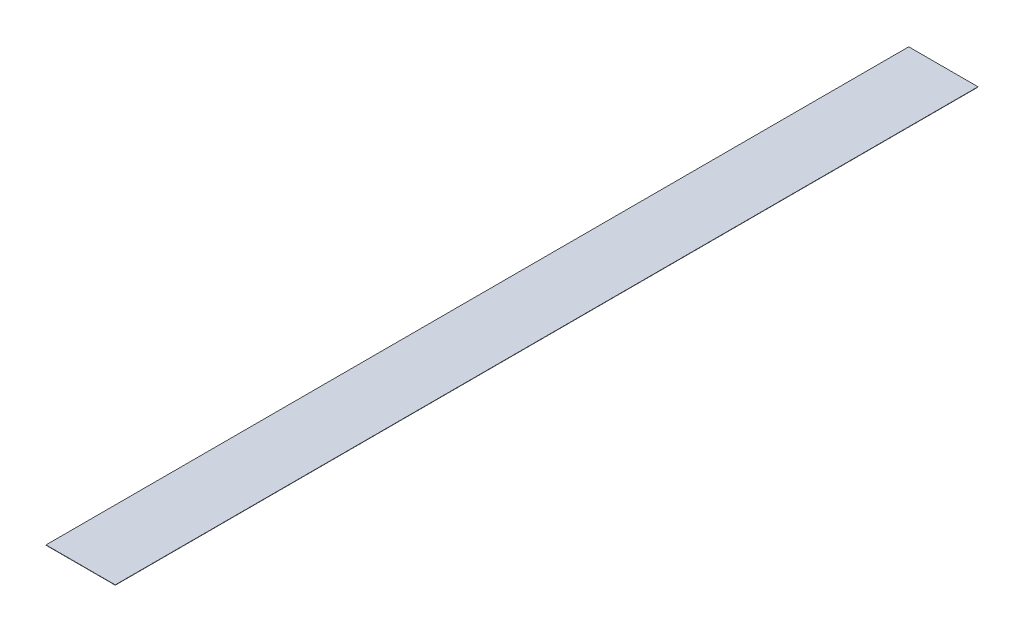
from build123d import *

# Parameters (mm, degrees)
SKETCH1_W      = 24.6054
SKETCH1_H      = 306.5
EXTRUDE1_DEPTH = 0.1


with BuildPart() as part:
    # Sketch1 → Extrude1 (new body)
    with BuildSketch(Plane(origin=(0, 0, 0), x_dir=(1, 0, 0), z_dir=(0, 1, 0))):
        Rectangle(SKETCH1_W, SKETCH1_H)
    extrude(amount=EXTRUDE1_DEPTH)


solid = part.part
